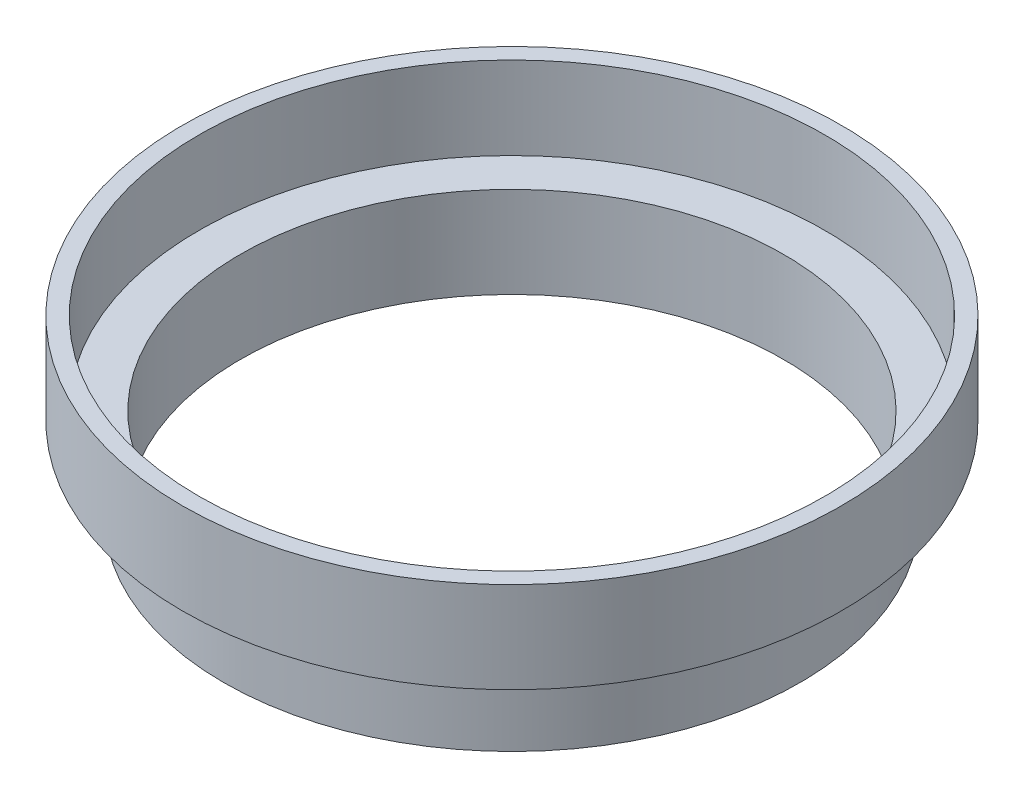
from build123d import *

# Parameters (mm, degrees)
SKETCH1_R           = 44.2214
SKETCH1_R_2         = 41.6814
BOSS_EXTRUDE1_DEPTH = 12.7
SKETCH2_R           = 50.5714
SKETCH2_R_2         = 41.6814
BOSS_EXTRUDE2_DEPTH = 1.27
SKETCH3_R           = 50.5714
SKETCH3_R_2         = 48.0314
BOSS_EXTRUDE3_DEPTH = 12.7


with BuildPart() as part:
    # Sketch1 → Boss-Extrude1 (new body)
    with BuildSketch(Plane(origin=(0, 0, 0), x_dir=(1, 0, 0), z_dir=(0, 1, 0))):
        Circle(SKETCH1_R)
        Circle(SKETCH1_R_2, mode=Mode.SUBTRACT)
    extrude(amount=BOSS_EXTRUDE1_DEPTH)

    # Sketch2 → Boss-Extrude2 (add)
    with BuildSketch(Plane(origin=(0, 12.7, 0), x_dir=(1, 0, 0), z_dir=(0, 1, 0))):
        Circle(SKETCH2_R)
        Circle(SKETCH2_R_2, mode=Mode.SUBTRACT)
    extrude(amount=BOSS_EXTRUDE2_DEPTH)

    # Sketch3 → Boss-Extrude3 (add)
    with BuildSketch(Plane(origin=(0, 13.97, 0), x_dir=(1, 0, 0), z_dir=(0, 1, 0))):
        Circle(SKETCH3_R)
        Circle(SKETCH3_R_2, mode=Mode.SUBTRACT)
    extrude(amount=BOSS_EXTRUDE3_DEPTH)


solid = part.part
